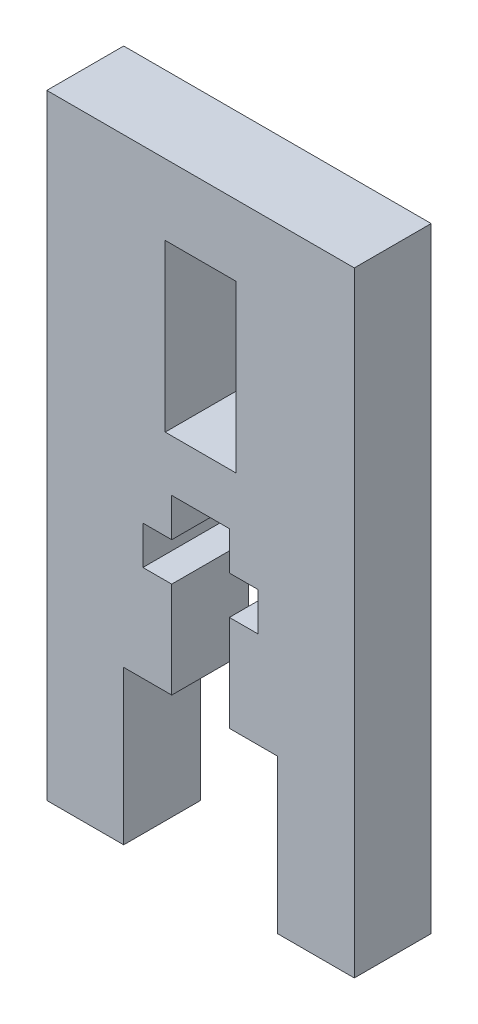
from build123d import *

# Parameters (mm, degrees)
BOSS_EXTRUDE1_DEPTH = 6.35
SKETCH8_W           = 4.7625
SKETCH8_H           = 14.2875
SKETCH8_W_2         = 9.525
SKETCH8_H_2         = 3.175
CUT_EXTRUDE5_DEPTH  = 6.35
SKETCH9_W           = 5.842
SKETCH9_H           = 13.716
CUT_EXTRUDE6_DEPTH  = 6.35


with BuildPart() as part:
    # Sketch7 → Boss-Extrude1 (new body)
    with BuildSketch(Plane.XY):
        Polygon((6.35, -25.4), (12.7, -25.4), (12.7, 25.4), (-12.7, 25.4), (-12.7, -25.4), (-6.35, -25.4), (-6.35, -12.7), (6.35, -12.7), align=None)
    extrude(amount=BOSS_EXTRUDE1_DEPTH)

    # Sketch8 → Cut-Extrude5 (cut)
    with BuildSketch(Plane.XY.offset(6.35)):
        with Locations((0, -5.55625)):
            Rectangle(SKETCH8_W, SKETCH8_H)
        with Locations((0, -3.175)):
            Rectangle(SKETCH8_W_2, SKETCH8_H_2)
    extrude(amount=-CUT_EXTRUDE5_DEPTH, mode=Mode.SUBTRACT)

    # Sketch9 → Cut-Extrude6 (cut)
    with BuildSketch(Plane.XY.offset(6.35)):
        with Locations((0, 12.7)):
            Rectangle(SKETCH9_W, SKETCH9_H)
    extrude(amount=-CUT_EXTRUDE6_DEPTH, mode=Mode.SUBTRACT)


solid = part.part
